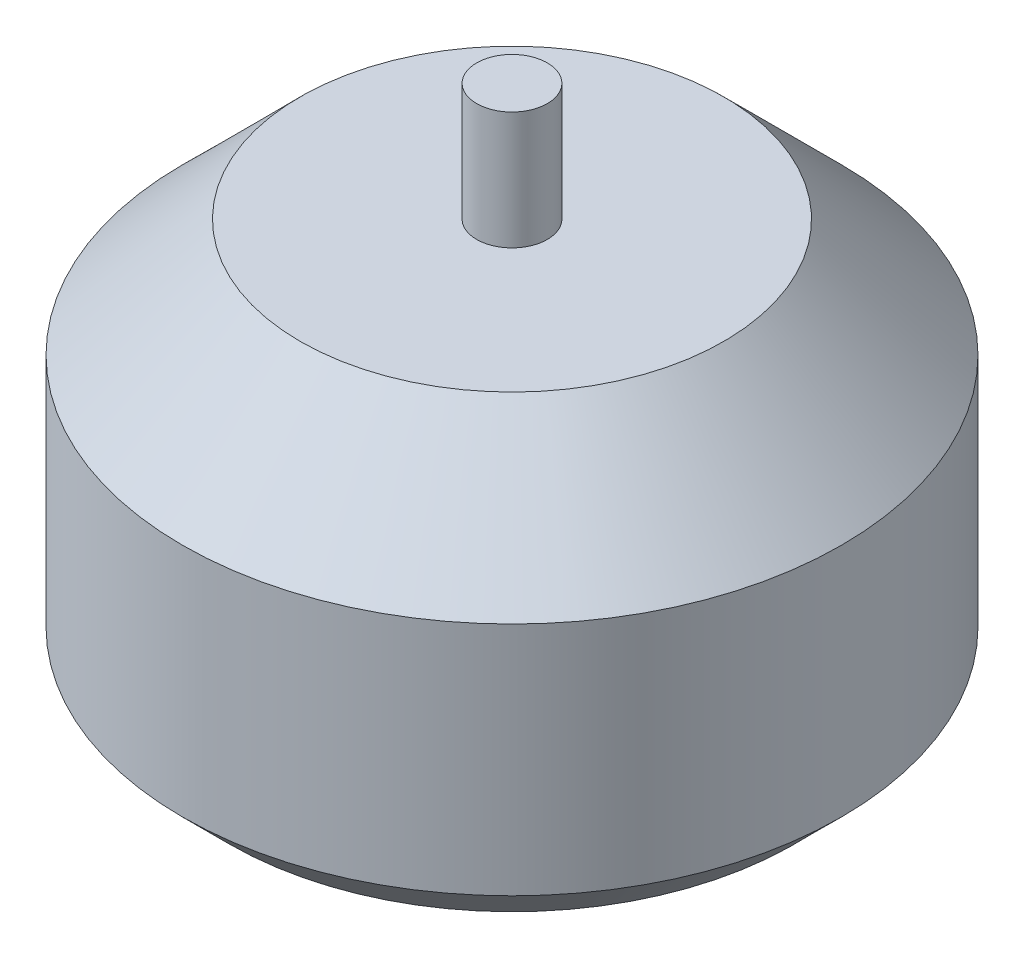
from build123d import *

# Parameters (mm, degrees)
SKETCH1_R           = 14
BOSS_EXTRUDE1_DEPTH = 17
CHAMFER1_SIZE       = 5
CHAMFER3_SIZE       = 2
SKETCH3_R           = 1.65
CUT_EXTRUDE1_DEPTH  = 5
SKETCH4_R           = 1.5
BOSS_EXTRUDE2_DEPTH = 5


with BuildPart() as part:
    # Sketch1 → Boss-Extrude1 (new body)
    with BuildSketch(Plane(origin=(0, 0, 0), x_dir=(1, 0, 0), z_dir=(0, 1, 0))):
        Circle(SKETCH1_R)
    extrude(amount=BOSS_EXTRUDE1_DEPTH)

    # Chamfer1
    chamfer1_edges = [part.edges().sort_by_distance(p)[0] for p in [
        (-14, 17, 0),
    ]]
    chamfer(chamfer1_edges, length=CHAMFER1_SIZE)

    # Chamfer3
    chamfer3_edges = [part.edges().sort_by_distance(p)[0] for p in [
        (-14, 0, 0),
    ]]
    chamfer(chamfer3_edges, length=CHAMFER3_SIZE)

    # Sketch3 → Cut-Extrude1 (cut)
    with BuildSketch(Plane.XZ):
        with Locations((0, 9.5)):
            Circle(SKETCH3_R)
        with Locations((0, -9.5)):
            Circle(SKETCH3_R)
        with Locations((-8, 0)):
            Circle(SKETCH3_R)
        with Locations((8, 0)):
            Circle(SKETCH3_R)
    extrude(amount=-CUT_EXTRUDE1_DEPTH, mode=Mode.SUBTRACT)

    # Sketch4 → Boss-Extrude2 (add)
    with BuildSketch(Plane(origin=(0, 17, 0), x_dir=(1, 0, 0), z_dir=(0, 1, 0))):
        Circle(SKETCH4_R)
    extrude(amount=BOSS_EXTRUDE2_DEPTH)


solid = part.part
